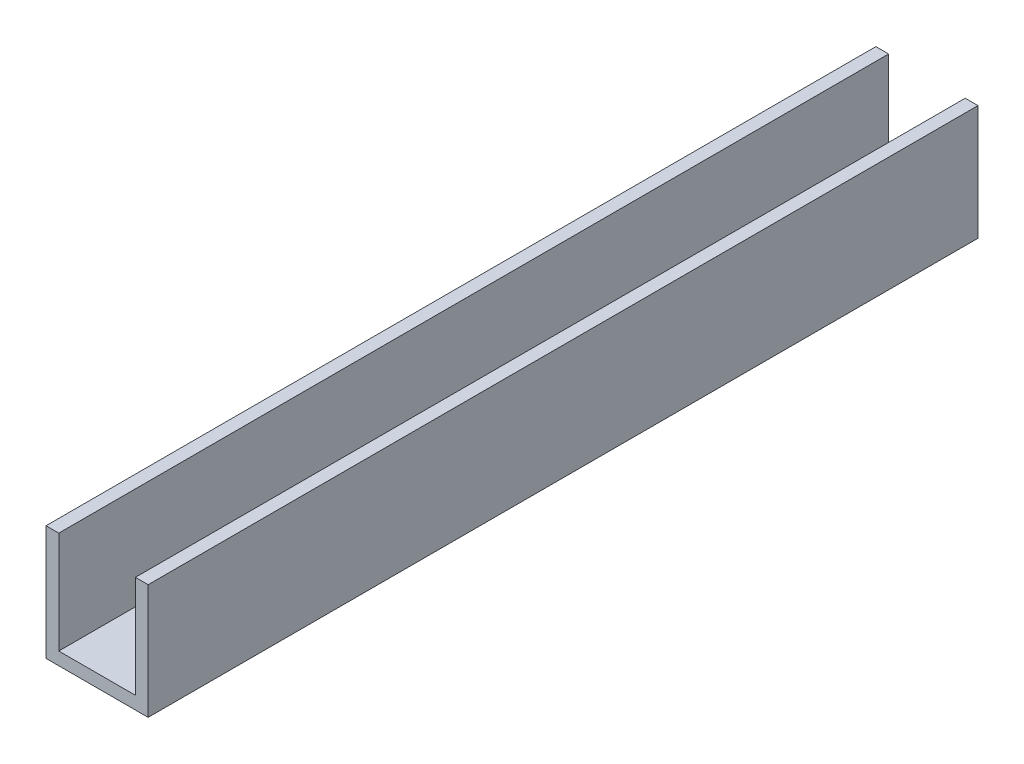
from build123d import *

# Parameters (mm, degrees)
SALIENTE_EXTRUIR1_DEPTH = 6500


with BuildPart() as part:
    # Croquis1 → Saliente-Extruir1 (new body)
    with BuildSketch(Plane.XY):
        Polygon((0, 0), (-800, 0), (-800, 900), (-700, 900), (-700, 100), (-100, 100), (-100, 900), (0, 900), align=None)
    extrude(amount=SALIENTE_EXTRUIR1_DEPTH)


solid = part.part
